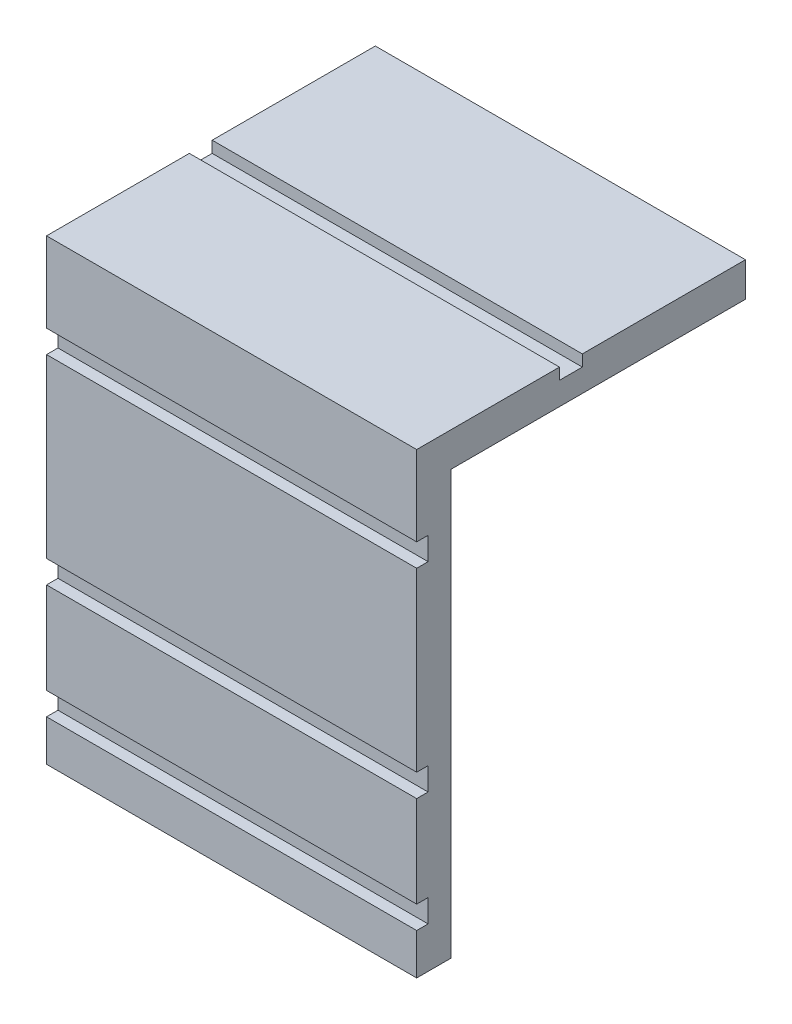
from build123d import *

# Parameters (mm, degrees)
BOSS_EXTRUDE1_DEPTH = 16.2


with BuildPart() as part:
    # Sketch1 → Boss-Extrude1 (new body)
    with BuildSketch(Plane(origin=(0, 0, 0), x_dir=(0, 0, -1), z_dir=(1, 0, 0))):
        Polygon((0, 0), (0, 1.8), (0.5, 1.8), (0.5, 2.8), (0, 2.8), (0, 6.8), (0.5, 6.8), (0.5, 7.8), (0, 7.8), (0, 15.53), (0.5, 15.53), (0.5, 16.53), (0, 16.53), (0, 20.03), (6.25, 20.03), (6.25, 19.53), (7.25, 19.53), (7.25, 20.03), (14.39, 20.03), (14.39, 18.53), (1.5, 18.53), (1.5, 0), align=None)
    extrude(amount=BOSS_EXTRUDE1_DEPTH)


solid = part.part
